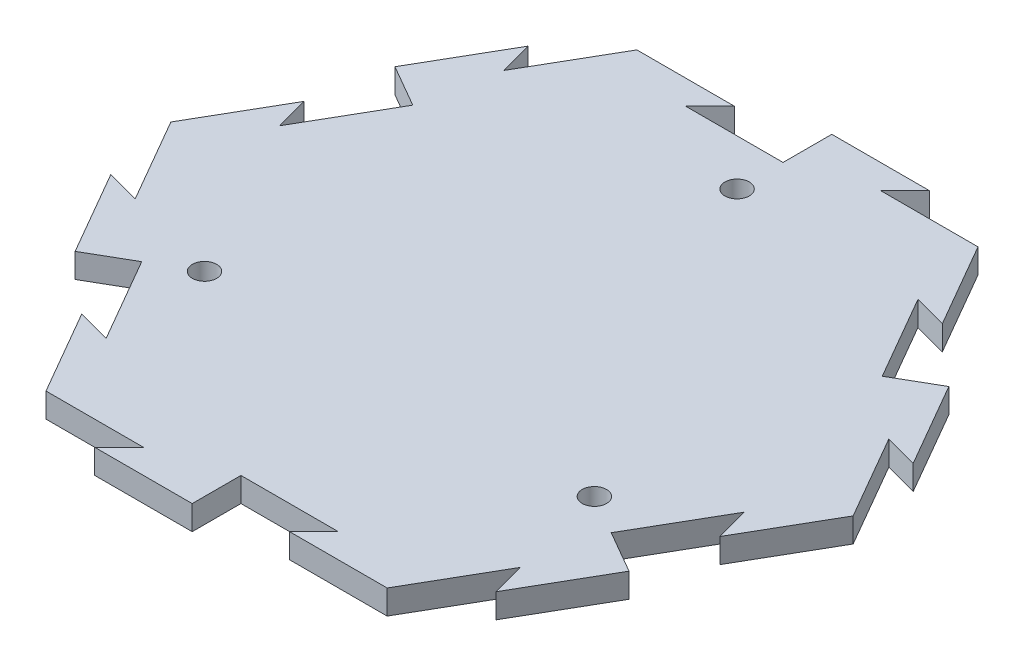
from build123d import *

# Parameters (mm, degrees)
BOSS_EXTRUDE1_DEPTH = 6.35
SKETCH9_R           = 3.175
CUT_EXTRUDE3_DEPTH  = 118.774954893
CIRPATTERN6_COUNT   = 3
CUT_EXTRUDE4_DEPTH  = 118.774954893
BOSS_EXTRUDE4_DEPTH = 6.35
CIRPATTERN7_COUNT   = 6


with BuildPart() as part:
    # Sketch1 → Boss-Extrude1 (new body)
    with BuildSketch(Plane(origin=(0, 0, 0), x_dir=(1, 0, 0), z_dir=(0, 1, 0))):
        Polygon((88.9, 0), (44.45, 76.989658396), (-44.45, 76.989658396), (-88.9, 0), (-44.45, -76.989658396), (44.45, -76.989658396), align=None)
    extrude(amount=-BOSS_EXTRUDE1_DEPTH)

    # Sketch9 → Cut-Extrude3 (cut, through all)
    with BuildSketch(Plane(origin=(0, 0, 0), x_dir=(1, 0, 0), z_dir=(0, 1, 0))):
        with Locations((-50.8, -29.329393675)):
            Circle(SKETCH9_R)
    cut_extrude3 = extrude(amount=-CUT_EXTRUDE3_DEPTH, mode=Mode.SUBTRACT)

    # CirPattern6: Cut-Extrude3 ×3 about axis
    cirpattern6_axis = Axis((0, 0, 0), (0, 1, 0))
    for i in range(1, CIRPATTERN6_COUNT):
        add(cut_extrude3.rotate(cirpattern6_axis, i * 360 / CIRPATTERN6_COUNT), mode=Mode.SUBTRACT)

    # Sketch10 → Cut-Extrude4 (cut, through all)
    with BuildSketch(Plane(origin=(0, 0, 0), x_dir=(1, 0, 0), z_dir=(0, 1, 0))):
        Polygon((57.15, 54.99261314), (48.475738686, 57.316874454), (61.175738686, 35.319829198), (66.675, 38.494829198), align=None)
    cut_extrude4 = extrude(amount=-CUT_EXTRUDE4_DEPTH, mode=Mode.SUBTRACT)

    # Sketch11 → Boss-Extrude4 (add)
    with BuildSketch(Plane(origin=(0, 0, 0), x_dir=(1, 0, 0), z_dir=(0, 1, 0))):
        Polygon((66.675, 38.494829198), (72.174261314, 41.669829198), (84.874261314, 19.672783942), (76.2, 21.997045256), align=None)
    boss_extrude4 = extrude(amount=-BOSS_EXTRUDE4_DEPTH)

    # CirPattern7: Cut-Extrude4, Boss-Extrude4 ×6 about axis
    cirpattern7_axis = Axis((0, 0, 0), (0, 1, 0))
    add([cut_extrude4.rotate(cirpattern7_axis, i * 360 / CIRPATTERN7_COUNT) for i in range(1, CIRPATTERN7_COUNT)], mode=Mode.SUBTRACT)
    add([boss_extrude4.rotate(cirpattern7_axis, i * 360 / CIRPATTERN7_COUNT) for i in range(1, CIRPATTERN7_COUNT)])


solid = part.part
